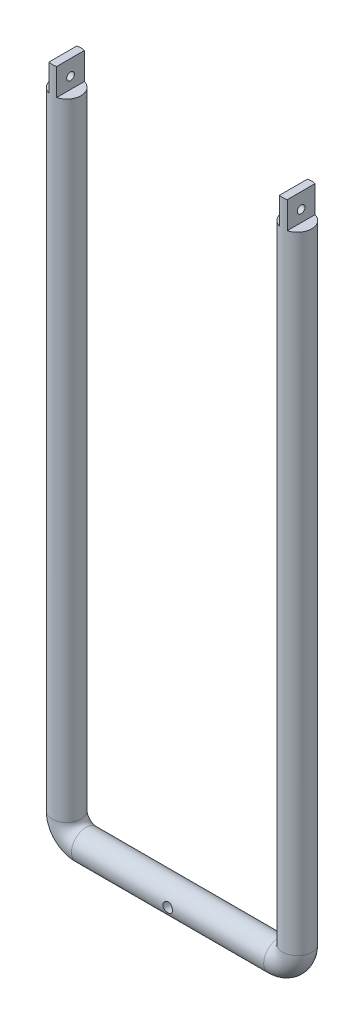
from build123d import *

# Parameters (mm, degrees)
SWEEP2_PROFILE_R   = 7.5
SKETCH41_W         = 5.5
SKETCH41_H         = 14
CUT_EXTRUDE1_DEPTH = 7.5
SKETCH40_R         = 2
CUT_EXTRUDE2_DEPTH = 65
SKETCH42_R         = 2.5
CUT_EXTRUDE3_DEPTH = 10


with BuildPart() as part:
    # Sweep2: sweep along a path in Sketch1
    with BuildLine(Plane.XY) as sweep2_path:
        Line((-60, 350), (-60, 10))
        ThreePointArc((-60, 10), (-57.071067812, 2.928932188), (-50, 0))
        Line((-50, 0), (50, 0))
        ThreePointArc((50, 0), (57.071067812, 2.928932188), (60, 10))
        Line((60, 10), (60, 350))
    # Sweep2 profile (on start of the path) → Sweep2 (sweep)
    with BuildSketch(Plane(origin=(-60, 350, 0), x_dir=(-1, 0, 0), z_dir=(0, -1, 0))):
        Circle(SWEEP2_PROFILE_R)
    sweep(path=sweep2_path.line)

    # Sketch41 → Cut-Extrude1 (cut, symmetric)
    with BuildSketch(Plane.XY):
        with Locations((-64.75, 343)):
            Rectangle(SKETCH41_W, SKETCH41_H)
        with Locations((-55.25, 343)):
            Rectangle(SKETCH41_W, SKETCH41_H)
        with Locations((55.25, 343)):
            Rectangle(SKETCH41_W, SKETCH41_H)
        with Locations((64.75, 343)):
            Rectangle(SKETCH41_W, SKETCH41_H)
    extrude(amount=CUT_EXTRUDE1_DEPTH, both=True, mode=Mode.SUBTRACT)

    # Sketch40 → Cut-Extrude2 (cut, symmetric)
    with BuildSketch(Plane(origin=(0, 0, 0), x_dir=(0, 0, -1), z_dir=(1, 0, 0))):
        with Locations((0, 342)):
            Circle(SKETCH40_R)
    extrude(amount=CUT_EXTRUDE2_DEPTH, both=True, mode=Mode.SUBTRACT)

    # Sketch42 → Cut-Extrude3 (cut, symmetric)
    with BuildSketch(Plane.XY):
        Circle(SKETCH42_R)
    extrude(amount=CUT_EXTRUDE3_DEPTH, both=True, mode=Mode.SUBTRACT)


solid = part.part
